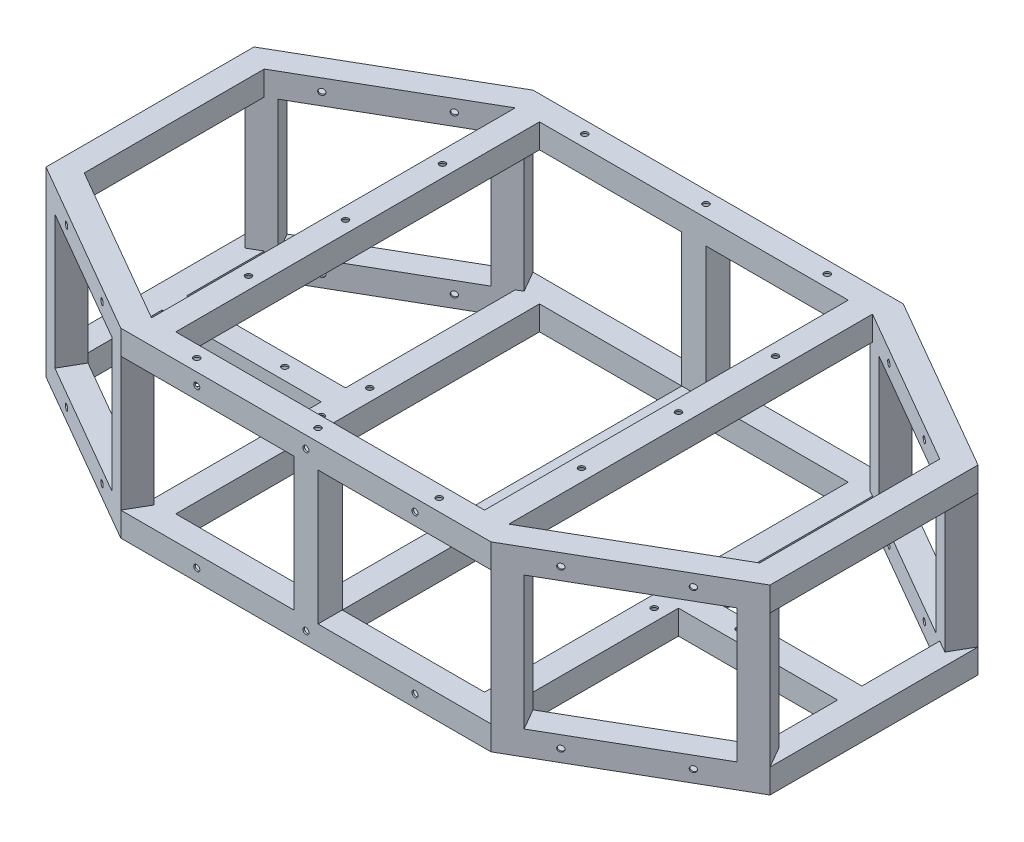
from build123d import *

# Parameters (mm, degrees)
SKETCH1_W                            = 25.4
SKETCH1_H                            = 25.4
SKETCH1_W_2                          = 22.098
SKETCH1_H_2                          = 22.098
VERTICAL_MEMBER_DEPTH                = 139.7
VERTICAL_MEMBER_2_DEPTH              = 139.7
MIRROR2_COPY_1_DEPTH                 = 139.7
MIRROR2_COPY_2_DEPTH                 = 139.7
SKETCH6_W                            = 25.4
SKETCH6_H                            = 25.4
SKETCH6_W_2                          = 22.098
SKETCH6_H_2                          = 22.098
BOSS_EXTRUDE3_DEPTH                  = 139.7
BOSS_EXTRUDE4_REACH                  = 408.4
SKETCH7_W                            = 25.4
SKETCH7_H                            = 25.4
SKETCH7_W_2                          = 22.098
SKETCH7_H_2                          = 22.098
SKETCH8_W                            = 25.4
SKETCH8_H                            = 25.4
SKETCH8_W_2                          = 22.098
SKETCH8_H_2                          = 22.098
BOSS_EXTRUDE5_DEPTH                  = 381
SKETCH9_W                            = 25.4
SKETCH9_H                            = 25.4
SKETCH9_W_2                          = 22.098
SKETCH9_H_2                          = 22.098
BOSS_EXTRUDE6_DEPTH                  = 166.679317
SKETCH10_W                           = 25.4
SKETCH10_H                           = 25.4
SKETCH10_W_2                         = 22.098
SKETCH10_H_2                         = 22.098
BOSS_EXTRUDE7_DEPTH                  = 381
F_1_4_0_25_DIAMETER_HOLE1_AT_2_COUNT = 2
F_1_4_0_25_DIAMETER_HOLE1_AT_2_PITCH = 101.6
SKETCH20_R                           = 3.175
CUT_EXTRUDE1_DEPTH                   = 1.651
SKETCH21_R                           = 3.175
CUT_EXTRUDE2_DEPTH                   = 50.8
CUT_EXTRUDE3_REACH                   = 433.8
SKETCH22_R                           = 3.175


with BuildPart() as part:
    # Sweep2: sweep along a path in Sketch2
    with BuildLine(Plane(origin=(0, 0, 0), x_dir=(1, 0, 0), z_dir=(0, 1, 0))) as sweep2_path:
        Line((190.5, 203.2), (-190.5, 203.2))
        Line((-190.5, 203.2), (-366.476362049, 101.6))
        Line((-366.476362049, 101.6), (-366.476362049, -101.6))
        Line((-366.476362049, -101.6), (-190.5, -203.2))
        Line((-190.5, -203.2), (190.5, -203.2))
        Line((190.5, -203.2), (366.476362049, -101.6))
        Line((366.476362049, -101.6), (366.476362049, 101.6))
        Line((366.476362049, 101.6), (190.5, 203.2))
    # Sketch1 → Sweep2 (sweep)
    with BuildSketch(Plane(origin=(0, 0, 0), x_dir=(0, 0, -1), z_dir=(1, 0, 0))):
        with Locations((203.2, 0)):
            Rectangle(SKETCH1_W, SKETCH1_H)
        with Locations((203.2, 0)):
            Rectangle(SKETCH1_W_2, SKETCH1_H_2, mode=Mode.SUBTRACT)
    sweep2 = sweep(path=sweep2_path.line, transition=Transition.RIGHT)

    # Sketch4 → Vertical Member (add)
    with BuildSketch(Plane(origin=(0, 12.7, 0), x_dir=(1, 0, 0), z_dir=(0, 1, 0))):
        Polygon((-193.902954744, -215.9), (-215.9, -203.2), (-203.2, -181.202954744), (-181.202954744, -193.902954744), align=None)
        Polygon((-213.644692058, -202.595692058), (-202.595692058, -183.458262686), (-183.458262686, -194.507262686), (-194.507262686, -213.644692058), align=None, mode=Mode.SUBTRACT)
    vertical_member = extrude(amount=VERTICAL_MEMBER_DEPTH)

    # Sketch5 → Vertical Member 2 (add)
    with BuildSketch(Plane(origin=(0, 12.7, 0), x_dir=(1, 0, 0), z_dir=(0, 1, 0))):
        Polygon((-379.176362049, -108.932348419), (-357.179316793, -121.632348419), (-344.479316793, -99.635303163), (-366.476362049, -86.935303163), align=None)
        Polygon((-376.921054107, -108.328040477), (-357.783624735, -119.377040477), (-346.734624735, -100.239611104), (-365.872054107, -89.190611104), align=None, mode=Mode.SUBTRACT)
    vertical_member_2 = extrude(amount=VERTICAL_MEMBER_2_DEPTH)

    # Mirror1: Vertical Member, Vertical Member 2 across plane
    add(vertical_member.mirror(Plane.XY))
    add(vertical_member_2.mirror(Plane.XY))

    # Mirror2: Vertical Member, Vertical Member 2 across plane
    add(vertical_member.mirror(Plane(origin=(0, 0, 0), x_dir=(0, 0, 1), z_dir=(1, 0, 0))))
    add(vertical_member_2.mirror(Plane(origin=(0, 0, 0), x_dir=(0, 0, 1), z_dir=(1, 0, 0))))

    # Mirror2 copy 1 sketch → Mirror2 copy 1 (add)
    with BuildSketch(Plane(origin=(0, 12.7, 0), x_dir=(-1, 0, 0), z_dir=(0, 1, 0))):
        Polygon((-193.902954744, -215.9), (-215.9, -203.2), (-203.2, -181.202954744), (-181.202954744, -193.902954744), align=None)
        Polygon((-213.644692058, -202.595692058), (-202.595692058, -183.458262686), (-183.458262686, -194.507262686), (-194.507262686, -213.644692058), align=None, mode=Mode.SUBTRACT)
    extrude(amount=MIRROR2_COPY_1_DEPTH)

    # Mirror2 copy 2 sketch → Mirror2 copy 2 (add)
    with BuildSketch(Plane(origin=(0, 12.7, 0), x_dir=(-1, 0, 0), z_dir=(0, 1, 0))):
        Polygon((-379.176362049, -108.932348419), (-357.179316793, -121.632348419), (-344.479316793, -99.635303163), (-366.476362049, -86.935303163), align=None)
        Polygon((-376.921054107, -108.328040477), (-357.783624735, -119.377040477), (-346.734624735, -100.239611104), (-365.872054107, -89.190611104), align=None, mode=Mode.SUBTRACT)
    extrude(amount=MIRROR2_COPY_2_DEPTH)

    # Sketch6 → Boss-Extrude3 (add)
    with BuildSketch(Plane(origin=(0, 12.7, 0), x_dir=(1, 0, 0), z_dir=(0, 1, 0))):
        with Locations((0, -203.2)):
            Rectangle(SKETCH6_W, SKETCH6_H)
        with Locations((0, -203.2)):
            Rectangle(SKETCH6_W_2, SKETCH6_H_2, mode=Mode.SUBTRACT)
    boss_extrude3 = extrude(amount=BOSS_EXTRUDE3_DEPTH)

    # Mirror3: Boss-Extrude3 across plane
    add(boss_extrude3.mirror(Plane.XY))

    # Mirror4: Sweep2 across plane
    add(sweep2.mirror(Plane.ZX.offset(82.55)))

    # Sketch7 → Boss-Extrude4 (add, up to next)
    with BuildSketch(Plane(origin=(0, 0, 190.5), x_dir=(-1, 0, 0), z_dir=(0, 0, -1)), mode=Mode.PRIVATE) as boss_extrude4_sk1:
        Rectangle(SKETCH7_W, SKETCH7_H)
        Rectangle(SKETCH7_W_2, SKETCH7_H_2, mode=Mode.SUBTRACT)
    boss_extrude4_tool1 = extrude(boss_extrude4_sk1.sketch, amount=BOSS_EXTRUDE4_REACH, mode=Mode.PRIVATE) - part.part
    add(boss_extrude4_tool1.solids().sort_by_distance((0, -12.34079, 190.5))[0])

    # Sketch8 → Boss-Extrude5 (add)
    with BuildSketch(Plane(origin=(0, 0, 190.5), x_dir=(-1, 0, 0), z_dir=(0, 0, -1))):
        with Locations((-174.397045256, 0)):
            Rectangle(SKETCH8_W, SKETCH8_H)
        with Locations((-174.397045256, 0)):
            Rectangle(SKETCH8_W_2, SKETCH8_H_2, mode=Mode.SUBTRACT)
    boss_extrude5 = extrude(amount=BOSS_EXTRUDE5_DEPTH)

    # Sketch9 → Boss-Extrude6 (add)
    with BuildSketch(Plane.ZY.offset(-353.776362049)):
        Rectangle(SKETCH9_W, SKETCH9_H)
        Rectangle(SKETCH9_W_2, SKETCH9_H_2, mode=Mode.SUBTRACT)
    boss_extrude6 = extrude(amount=BOSS_EXTRUDE6_DEPTH)

    # Mirror5: Boss-Extrude5, Boss-Extrude6 across plane
    add(boss_extrude5.mirror(Plane(origin=(0, 0, 0), x_dir=(0, 0, 1), z_dir=(1, 0, 0))))
    add(boss_extrude6.mirror(Plane(origin=(0, 0, 0), x_dir=(0, 0, 1), z_dir=(1, 0, 0))))

    # Sketch10 → Boss-Extrude7 (add)
    with BuildSketch(Plane.XY.offset(-190.5)):
        with Locations((-174.397045256, 165.1)):
            Rectangle(SKETCH10_W, SKETCH10_H)
        with Locations((-174.397045256, 165.1)):
            Rectangle(SKETCH10_W_2, SKETCH10_H_2, mode=Mode.SUBTRACT)
    boss_extrude7 = extrude(amount=BOSS_EXTRUDE7_DEPTH)

    # Mirror6: Boss-Extrude7 across plane
    add(boss_extrude7.mirror(Plane(origin=(0, 0, 0), x_dir=(0, 0, 1), z_dir=(1, 0, 0))))

    # Sketch19 → 1/4 (0.25) Diameter Hole1 (revolve, cut)
    with BuildSketch(Plane(origin=(-328.261713498, 165.1, 138.327934465), x_dir=(0.866025404, 0, 0.5), z_dir=(0, 1, 0))):
        Polygon((0, 0), (0, 52.707732465), (3.175, 50.8), (3.175, 0), align=None)
    f_1_4_0_25_diameter_hole1 = revolve(axis=Axis((-331.436713498, 165.1, 143.827195779), (0.5, 0, -0.866025404)), mode=Mode.SUBTRACT)

    # 1/4 (0.25) Diameter Hole1 at 2: 1/4 (0.25) Diameter Hole1 ×2
    with Locations(*[Vector(0.866025404, 0, 0.5) * (i * F_1_4_0_25_DIAMETER_HOLE1_AT_2_PITCH) for i in range(1, F_1_4_0_25_DIAMETER_HOLE1_AT_2_COUNT)]):
        add(f_1_4_0_25_diameter_hole1, mode=Mode.SUBTRACT)

    # Mirror7: 1/4 (0.25) Diameter Hole1 across plane
    add(f_1_4_0_25_diameter_hole1.mirror(Plane.ZX.offset(82.55)), mode=Mode.SUBTRACT)

    # Mirror7 copy 1 sketch → Mirror7 copy 1 (revolve, cut)
    with BuildSketch(Plane(origin=(-240.273532474, 0, 189.127934465), x_dir=(0.866025404, 0, 0.5), z_dir=(0, -1, 0))):
        Polygon((0, 0), (0, -52.707732465), (3.175, -50.8), (3.175, 0), align=None)
    revolve(axis=Axis((-243.448532474, 0, 194.627195779), (-0.5, 0, 0.866025404)), mode=Mode.SUBTRACT)

    # Mirror8: 1/4 (0.25) Diameter Hole1 across plane
    add(f_1_4_0_25_diameter_hole1.mirror(Plane.XY), mode=Mode.SUBTRACT)

    # Mirror8 copy 1 sketch → Mirror8 copy 1 (revolve, cut)
    with BuildSketch(Plane(origin=(-328.261713498, 0, -138.327934465), x_dir=(0.866025404, 0, -0.5), z_dir=(0, -1, 0))):
        Polygon((0, 0), (0, 52.707732465), (3.175, 50.8), (3.175, 0), align=None)
    revolve(axis=Axis((-331.436713498, 0, -143.827195779), (0.5, 0, 0.866025404)), mode=Mode.SUBTRACT)

    # Mirror8 copy 2 sketch → Mirror8 copy 2 (revolve, cut)
    with BuildSketch(Plane(origin=(-240.273532474, 0, -189.127934465), x_dir=(0.866025404, 0, -0.5), z_dir=(0, -1, 0))):
        Polygon((0, 0), (0, 52.707732465), (3.175, 50.8), (3.175, 0), align=None)
    revolve(axis=Axis((-243.448532474, 0, -194.627195779), (0.5, 0, 0.866025404)), mode=Mode.SUBTRACT)

    # Mirror8 copy 3 sketch → Mirror8 copy 3 (revolve, cut)
    with BuildSketch(Plane(origin=(-240.273532474, 165.1, -189.127934465), x_dir=(0.866025404, 0, -0.5), z_dir=(0, 1, 0))):
        Polygon((0, 0), (0, -52.707732465), (3.175, -50.8), (3.175, 0), align=None)
    revolve(axis=Axis((-243.448532474, 165.1, -194.627195779), (-0.5, 0, -0.866025404)), mode=Mode.SUBTRACT)

    # Mirror9: 1/4 (0.25) Diameter Hole1 across plane
    add(f_1_4_0_25_diameter_hole1.mirror(Plane(origin=(0, 0, 0), x_dir=(0, 0, 1), z_dir=(1, 0, 0))), mode=Mode.SUBTRACT)

    # Mirror9 copy 1 sketch → Mirror9 copy 1 (revolve, cut)
    with BuildSketch(Plane(origin=(328.261713498, 165.1, -138.327934465), x_dir=(-0.866025404, 0, -0.5), z_dir=(0, 1, 0))):
        Polygon((0, 0), (0, 52.707732465), (3.175, 50.8), (3.175, 0), align=None)
    revolve(axis=Axis((331.436713498, 165.1, -143.827195779), (-0.5, 0, 0.866025404)), mode=Mode.SUBTRACT)

    # Mirror9 copy 2 sketch → Mirror9 copy 2 (revolve, cut)
    with BuildSketch(Plane(origin=(328.261713498, 0, -138.327934465), x_dir=(-0.866025404, 0, -0.5), z_dir=(0, -1, 0))):
        Polygon((0, 0), (0, -52.707732465), (3.175, -50.8), (3.175, 0), align=None)
    revolve(axis=Axis((331.436713498, 0, -143.827195779), (0.5, 0, -0.866025404)), mode=Mode.SUBTRACT)

    # Mirror9 copy 3 sketch → Mirror9 copy 3 (revolve, cut)
    with BuildSketch(Plane(origin=(240.273532474, 0, -189.127934465), x_dir=(-0.866025404, 0, -0.5), z_dir=(0, -1, 0))):
        Polygon((0, 0), (0, -52.707732465), (3.175, -50.8), (3.175, 0), align=None)
    revolve(axis=Axis((243.448532474, 0, -194.627195779), (0.5, 0, -0.866025404)), mode=Mode.SUBTRACT)

    # Mirror9 copy 4 sketch → Mirror9 copy 4 (revolve, cut)
    with BuildSketch(Plane(origin=(240.273532474, 165.1, -189.127934465), x_dir=(-0.866025404, 0, -0.5), z_dir=(0, 1, 0))):
        Polygon((0, 0), (0, 52.707732465), (3.175, 50.8), (3.175, 0), align=None)
    revolve(axis=Axis((243.448532474, 165.1, -194.627195779), (-0.5, 0, 0.866025404)), mode=Mode.SUBTRACT)

    # Mirror9 copy 5 sketch → Mirror9 copy 5 (revolve, cut)
    with BuildSketch(Plane(origin=(328.261713498, 0, 138.327934465), x_dir=(-0.866025404, 0, 0.5), z_dir=(0, -1, 0))):
        Polygon((0, 0), (0, 52.707732465), (3.175, 50.8), (3.175, 0), align=None)
    revolve(axis=Axis((331.436713498, 0, 143.827195779), (-0.5, 0, -0.866025404)), mode=Mode.SUBTRACT)

    # Mirror9 copy 6 sketch → Mirror9 copy 6 (revolve, cut)
    with BuildSketch(Plane(origin=(240.273532474, 0, 189.127934465), x_dir=(-0.866025404, 0, 0.5), z_dir=(0, -1, 0))):
        Polygon((0, 0), (0, 52.707732465), (3.175, 50.8), (3.175, 0), align=None)
    revolve(axis=Axis((243.448532474, 0, 194.627195779), (-0.5, 0, -0.866025404)), mode=Mode.SUBTRACT)

    # Mirror9 copy 7 sketch → Mirror9 copy 7 (revolve, cut)
    with BuildSketch(Plane(origin=(240.273532474, 165.1, 189.127934465), x_dir=(-0.866025404, 0, 0.5), z_dir=(0, 1, 0))):
        Polygon((0, 0), (0, -52.707732465), (3.175, -50.8), (3.175, 0), align=None)
    revolve(axis=Axis((243.448532474, 165.1, 194.627195779), (0.5, 0, 0.866025404)), mode=Mode.SUBTRACT)

    # Sketch20 → Cut-Extrude1 (cut)
    with BuildSketch(Plane(origin=(0, 12.7, 0), x_dir=(1, 0, 0), z_dir=(0, 1, 0))):
        with Locations((-174.397045256, -25.4)):
            Circle(SKETCH20_R)
        with Locations((-237.897045256, 0)):
            Circle(SKETCH20_R)
        with Locations((-174.397045256, 25.4)):
            Circle(SKETCH20_R)
    cut_extrude1 = extrude(amount=-CUT_EXTRUDE1_DEPTH, mode=Mode.SUBTRACT)

    # Mirror10: Cut-Extrude1 across plane
    add(cut_extrude1.mirror(Plane(origin=(0, 0, 0), x_dir=(0, 0, 1), z_dir=(1, 0, 0))), mode=Mode.SUBTRACT)

    # Sketch21 → Cut-Extrude2 (cut)
    with BuildSketch(Plane(origin=(0, 177.8, 0), x_dir=(1, 0, 0), z_dir=(0, 1, 0))):
        with Locations((-174.397045256, 101.6)):
            Circle(SKETCH21_R)
        with Locations((-174.397045256, 0)):
            Circle(SKETCH21_R)
        with Locations((-174.397045256, -101.6)):
            Circle(SKETCH21_R)
        with Locations((-127, -203.2)):
            Circle(SKETCH21_R)
        with Locations((0, -203.2)):
            Circle(SKETCH21_R)
        with Locations((127, -203.2)):
            Circle(SKETCH21_R)
        with Locations((174.397045256, 101.6)):
            Circle(SKETCH21_R)
        with Locations((174.397045256, 0)):
            Circle(SKETCH21_R)
        with Locations((174.397045256, -101.6)):
            Circle(SKETCH21_R)
        with Locations((127, 203.2)):
            Circle(SKETCH21_R)
        with Locations((0, 203.2)):
            Circle(SKETCH21_R)
        with Locations((-127, 203.2)):
            Circle(SKETCH21_R)
    extrude(amount=-CUT_EXTRUDE2_DEPTH, mode=Mode.SUBTRACT)

    # Sketch22 → Cut-Extrude3 (cut, up to next)
    with BuildSketch(Plane.XY.offset(215.9), mode=Mode.PRIVATE) as cut_extrude3_sk1:
        with Locations((-114.3, 165.1)):
            Circle(SKETCH22_R)
    cut_extrude3_tool1 = extrude(cut_extrude3_sk1.sketch, amount=-CUT_EXTRUDE3_REACH, mode=Mode.PRIVATE) & part.part
    add(cut_extrude3_tool1.solids().sort_by_distance((-114.3, 165.1, 215.9))[0], mode=Mode.SUBTRACT)
    # Sketch22 → Cut-Extrude3 (cut, up to next)
    with BuildSketch(Plane.XY.offset(215.9), mode=Mode.PRIVATE) as cut_extrude3_sk2:
        with Locations((0, 165.1)):
            Circle(SKETCH22_R)
    cut_extrude3_tool2 = extrude(cut_extrude3_sk2.sketch, amount=-CUT_EXTRUDE3_REACH, mode=Mode.PRIVATE) & part.part
    add(cut_extrude3_tool2.solids().sort_by_distance((0, 165.1, 215.9))[0], mode=Mode.SUBTRACT)
    # Sketch22 → Cut-Extrude3 (cut, up to next)
    with BuildSketch(Plane.XY.offset(215.9), mode=Mode.PRIVATE) as cut_extrude3_sk3:
        with Locations((114.3, 165.1)):
            Circle(SKETCH22_R)
    cut_extrude3_tool3 = extrude(cut_extrude3_sk3.sketch, amount=-CUT_EXTRUDE3_REACH, mode=Mode.PRIVATE) & part.part
    add(cut_extrude3_tool3.solids().sort_by_distance((114.3, 165.1, 215.9))[0], mode=Mode.SUBTRACT)
    # Sketch22 → Cut-Extrude3 (cut, up to next)
    with BuildSketch(Plane.XY.offset(215.9), mode=Mode.PRIVATE) as cut_extrude3_sk4:
        with Locations((-114.3, 0)):
            Circle(SKETCH22_R)
    cut_extrude3_tool4 = extrude(cut_extrude3_sk4.sketch, amount=-CUT_EXTRUDE3_REACH, mode=Mode.PRIVATE) & part.part
    add(cut_extrude3_tool4.solids().sort_by_distance((-114.3, 0, 215.9))[0], mode=Mode.SUBTRACT)
    # Sketch22 → Cut-Extrude3 (cut, up to next)
    with BuildSketch(Plane.XY.offset(215.9), mode=Mode.PRIVATE) as cut_extrude3_sk5:
        Circle(SKETCH22_R)
    cut_extrude3_tool5 = extrude(cut_extrude3_sk5.sketch, amount=-CUT_EXTRUDE3_REACH, mode=Mode.PRIVATE) & part.part
    add(cut_extrude3_tool5.solids().sort_by_distance((0, 0, 215.9))[0], mode=Mode.SUBTRACT)
    # Sketch22 → Cut-Extrude3 (cut, up to next)
    with BuildSketch(Plane.XY.offset(215.9), mode=Mode.PRIVATE) as cut_extrude3_sk6:
        with Locations((114.3, 0)):
            Circle(SKETCH22_R)
    cut_extrude3_tool6 = extrude(cut_extrude3_sk6.sketch, amount=-CUT_EXTRUDE3_REACH, mode=Mode.PRIVATE) & part.part
    add(cut_extrude3_tool6.solids().sort_by_distance((114.3, 0, 215.9))[0], mode=Mode.SUBTRACT)


solid = part.part
